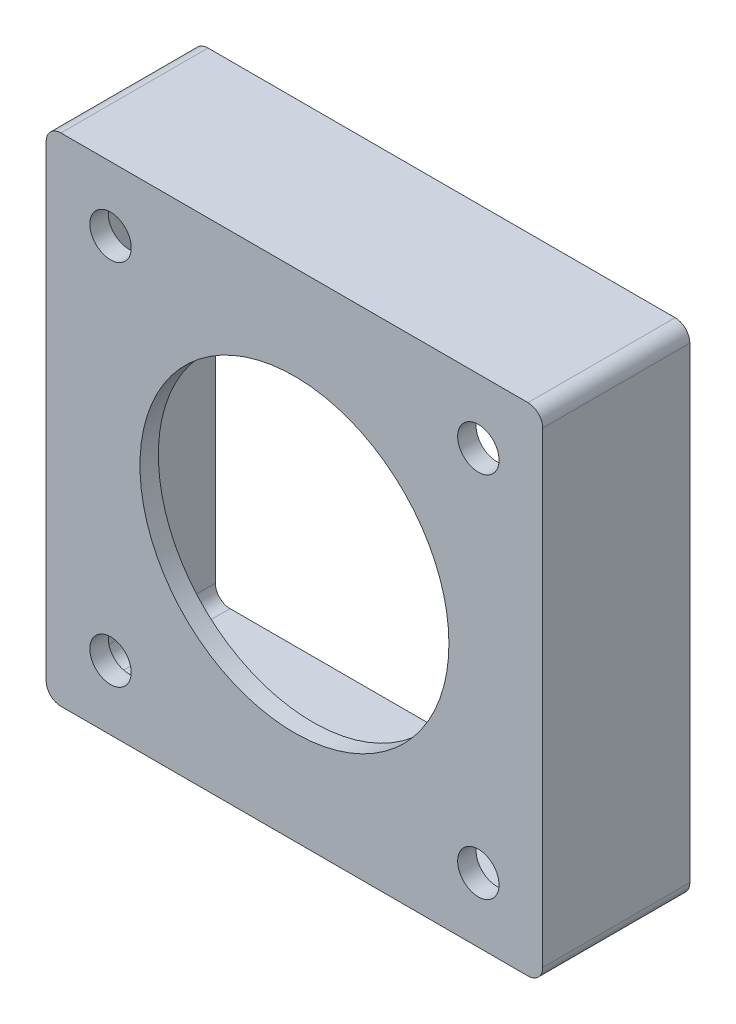
from build123d import *

# Parameters (mm, degrees)
SKETCH1_W               = 85.725
SKETCH1_H               = 85.725
SKETCH1_R               = 26.67
BOSS_EXTRUDE1_DEPTH     = 25.4
SKETCH2_R               = 3.572453457
CUT_EXTRUDE1_DEPTH      = 26.4
MIRROR2_COPY_1_SKETCH_R = 3.572453457
MIRROR2_COPY_1_DEPTH    = 26.4
SKETCH3_W               = 78.105
SKETCH3_H               = 78.105
CUT_EXTRUDE2_DEPTH      = 22.225
FILLET1_R               = 2.54


with BuildPart() as part:
    # Sketch1 → Boss-Extrude1 (new body)
    with BuildSketch(Plane.XY):
        Rectangle(SKETCH1_W, SKETCH1_H)
        Circle(SKETCH1_R, mode=Mode.SUBTRACT)
    extrude(amount=BOSS_EXTRUDE1_DEPTH)

    # Sketch2 → Cut-Extrude1 (cut, through all)
    with BuildSketch(Plane.XY.offset(25.4)):
        with Locations((-31.75, 31.75)):
            Circle(SKETCH2_R)
    cut_extrude1 = extrude(amount=-CUT_EXTRUDE1_DEPTH, mode=Mode.SUBTRACT)

    # Mirror1: Cut-Extrude1 across plane
    add(cut_extrude1.mirror(Plane(origin=(0, 0, 0), x_dir=(0, 0, 1), z_dir=(1, 0, 0))), mode=Mode.SUBTRACT)

    # Mirror2: Cut-Extrude1 across plane
    add(cut_extrude1.mirror(Plane.ZX), mode=Mode.SUBTRACT)

    # Mirror2 copy 1 sketch → Mirror2 copy 1 (cut, through all)
    with BuildSketch(Plane(origin=(0, 0, 25.4), x_dir=(-1, 0, 0), z_dir=(0, 0, 1))):
        with Locations((-31.75, 31.75)):
            Circle(MIRROR2_COPY_1_SKETCH_R)
    extrude(amount=-MIRROR2_COPY_1_DEPTH, mode=Mode.SUBTRACT)

    # Sketch3 → Cut-Extrude2 (cut)
    with BuildSketch(Plane(origin=(0, 0, 0), x_dir=(-1, 0, 0), z_dir=(0, 0, -1))):
        Rectangle(SKETCH3_W, SKETCH3_H)
    extrude(amount=-CUT_EXTRUDE2_DEPTH, mode=Mode.SUBTRACT)

    # Fillet1
    fillet1_edges = [part.edges().sort_by_distance(p)[0] for p in [
        (-39.0525, -39.0525, 11.1125),
        (-39.0525, 39.0525, 11.1125),
        (39.0525, 39.0525, 11.1125),
        (39.0525, -39.0525, 11.1125),
        (-42.8625, 42.8625, 12.7),
        (42.8625, 42.8625, 12.7),
        (42.8625, -42.8625, 12.7),
        (-42.8625, -42.8625, 12.7),
    ]]
    fillet(fillet1_edges, radius=FILLET1_R)


solid = part.part
